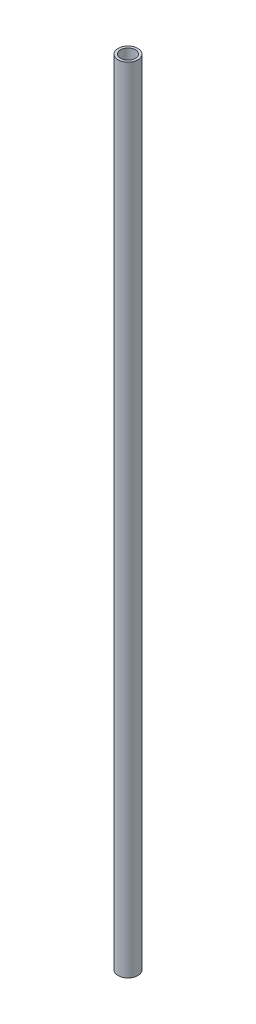
from build123d import *

# Parameters (mm, degrees)
SKETCH1_R           = 2
SKETCH1_R_2         = 1.5
BOSS_EXTRUDE1_DEPTH = 160


with BuildPart() as part:
    # Sketch1 → Boss-Extrude1 (new body)
    with BuildSketch(Plane(origin=(0, 0, 0), x_dir=(1, 0, 0), z_dir=(0, 1, 0))):
        Circle(SKETCH1_R)
        Circle(SKETCH1_R_2, mode=Mode.SUBTRACT)
    extrude(amount=BOSS_EXTRUDE1_DEPTH)


solid = part.part
